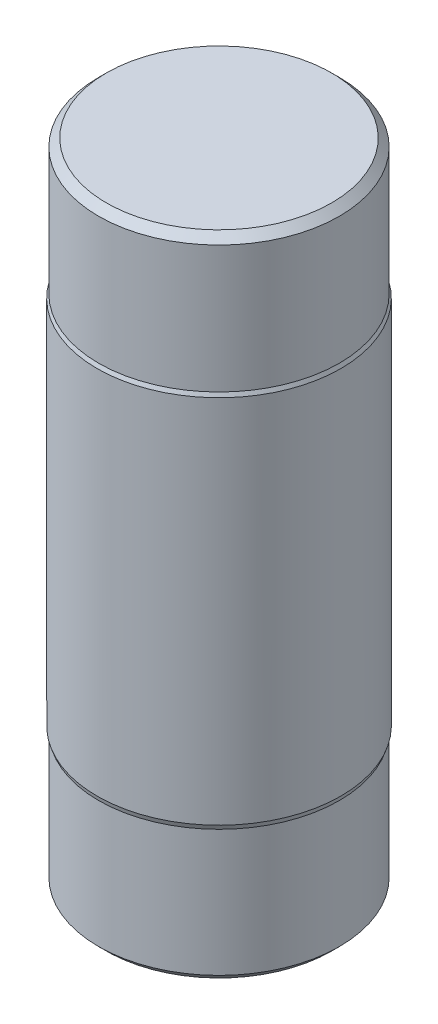
from build123d import *

# Parameters (mm, degrees)
SKETCH1_R           = 3.95
BOSS_EXTRUDE1_DEPTH = 6
CHAMFER1_SIZE       = 0.25


with BuildPart() as part:
    # Sketch1 → Boss-Extrude1 (new, symmetric)
    with BuildSketch(Plane(origin=(0, 0, 0), x_dir=(1, 0, 0), z_dir=(0, 1, 0))):
        with Locations(Location((0, 0, 0), (0, 0, 270))):
            Circle(SKETCH1_R)
    extrude(amount=BOSS_EXTRUDE1_DEPTH, both=True)

    # Sketch2 → Revolve2 (revolve)
    with BuildSketch(Plane.XY, mode=Mode.PRIVATE) as revolve2_sk:
        Polygon((0, -10.5), (0, -6), (-3.95, -6), (-3.9, -6.15), (-3.9, -10.5), align=None)
        Polygon((0, 10.5), (0, 6), (3.95, 6), (3.9, 6.125), (3.9, 10.5), align=None)
    revolve(revolve2_sk.sketch.rotate(Axis((0, -10.5, 0), (0, 1, 0)), 180), axis=Axis((0, -10.5, 0), (0, 1, 0)))

    # Chamfer1
    chamfer1_edges = [part.edges().sort_by_distance(p)[0] for p in [
        (-3.9, -10.5, 0),
        (3.9, 10.5, 0),
    ]]
    chamfer(chamfer1_edges, length=CHAMFER1_SIZE)


solid = part.part
